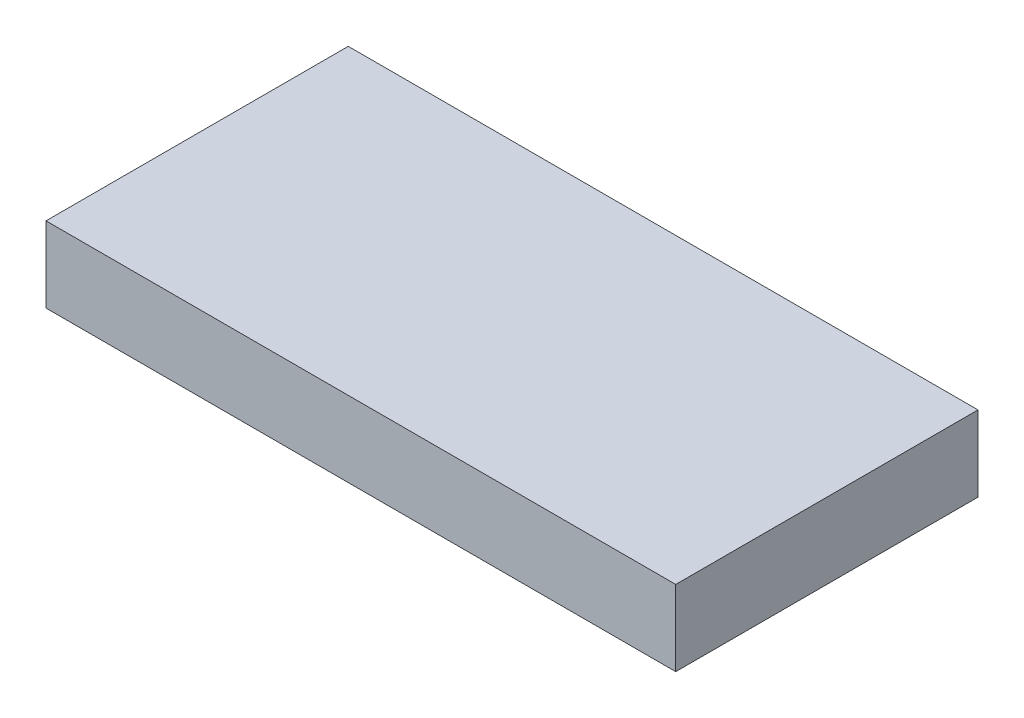
from build123d import *

# Parameters (mm, degrees)
SKETCH1_W           = 250
SKETCH1_H           = 120
BOSS_EXTRUDE1_DEPTH = 30


with BuildPart() as part:
    # Sketch1 → Boss-Extrude1 (new body)
    with BuildSketch(Plane(origin=(0, 0, 0), x_dir=(1, 0, 0), z_dir=(0, 1, 0))):
        Rectangle(SKETCH1_W, SKETCH1_H)
    extrude(amount=BOSS_EXTRUDE1_DEPTH)


solid = part.part
